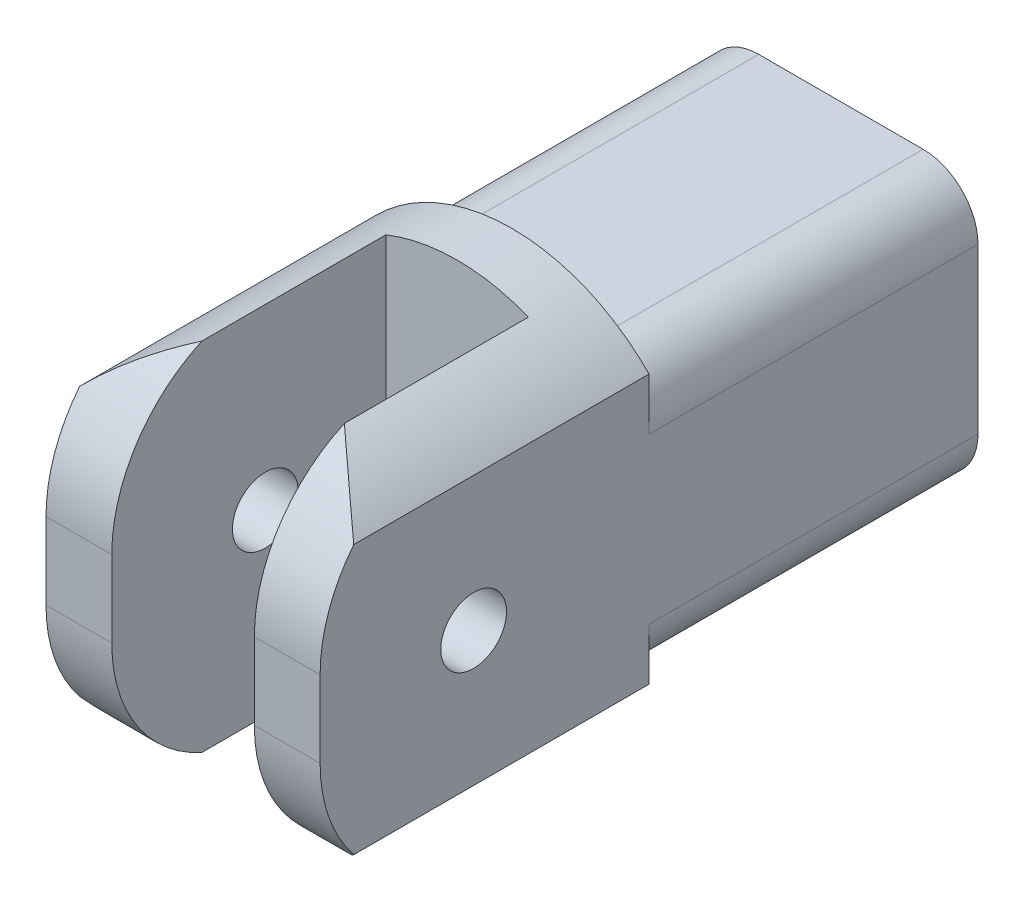
from build123d import *

# Parameters (mm, degrees)
SKETCH1_R           = 3
BOSS_EXTRUDE1_DEPTH = 25
SKETCH3_R           = 6.4
CUT_EXTRUDE2_DEPTH  = 108
SKETCH4_W           = 13
SKETCH4_H           = 40.487648952
CUT_EXTRUDE3_DEPTH  = 25
FILLET2_R           = 5
SKETCH5_OUTSIDE_W   = 41.764
SKETCH5_OUTSIDE_H   = 51.764
SKETCH5_OUTSIDE_R   = 17.5
CUT_EXTRUDE5_DEPTH  = 39


with BuildPart() as part:
    # Sketch1 → Boss-Extrude1 (new body)
    with BuildSketch(Plane(origin=(0, 0, 0), x_dir=(0, 0, -1), z_dir=(1, 0, 0))):
        with BuildLine():
            Line((67.738148954, 12.5), (37.738148954, 12.5))
            Line((37.738148954, 12.5), (37.738148954, 17.5))
            Line((37.738148954, 17.5), (21.738148954, 17.5))
            ThreePointArc((21.738148954, 17.5), (11.838654018, 13.399494937), (7.738148954, 3.5))
            Line((7.738148954, 3.5), (7.738148954, -3.5))
            ThreePointArc((7.738148954, -3.5), (11.838654018, -13.399494937), (21.738148954, -17.5))
            Line((21.738148954, -17.5), (37.738148954, -17.5))
            Line((37.738148954, -17.5), (37.738148954, -12.5))
            Line((37.738148954, -12.5), (67.738148954, -12.5))
            Line((67.738148954, -12.5), (67.738148954, 12.5))
        make_face()
        with Locations((21.738148954, 0)):
            Circle(SKETCH1_R, mode=Mode.SUBTRACT)
    extrude(amount=BOSS_EXTRUDE1_DEPTH)

    # Sketch3 → Cut-Extrude2 (cut)
    with BuildSketch(Plane(origin=(0, 0, -67.738148954), x_dir=(-1, 0, 0), z_dir=(0, 0, -1))):
        with Locations((-12.5, 0)):
            Circle(SKETCH3_R)
    extrude(amount=-CUT_EXTRUDE2_DEPTH, mode=Mode.SUBTRACT)

    # Sketch4 → Cut-Extrude3 (cut)
    with BuildSketch(Plane.XY.offset(-7.738148954)):
        with Locations((12.5, 0)):
            Rectangle(SKETCH4_W, SKETCH4_H)
    extrude(amount=-CUT_EXTRUDE3_DEPTH, mode=Mode.SUBTRACT)

    # Fillet2
    fillet2_edges = [part.edges().sort_by_distance(p)[0] for p in [
        (0, 12.5, -52.738148954),
        (25, -12.5, -52.738148954),
        (25, 12.5, -52.738148954),
        (0, -12.5, -52.738148954),
    ]]
    fillet(fillet2_edges, radius=FILLET2_R)

    # Sketch5 outside → Cut-Extrude5 (cut)
    with BuildSketch(Plane(origin=(0, 0, -37.738148954), x_dir=(-1, 0, 0), z_dir=(0, 0, -1))):
        with Locations((-12.5, 0)):
            Rectangle(SKETCH5_OUTSIDE_W, SKETCH5_OUTSIDE_H)
        with Locations((-12.5, 0)):
            Circle(SKETCH5_OUTSIDE_R, mode=Mode.SUBTRACT)
    extrude(amount=-CUT_EXTRUDE5_DEPTH, mode=Mode.SUBTRACT)


solid = part.part
